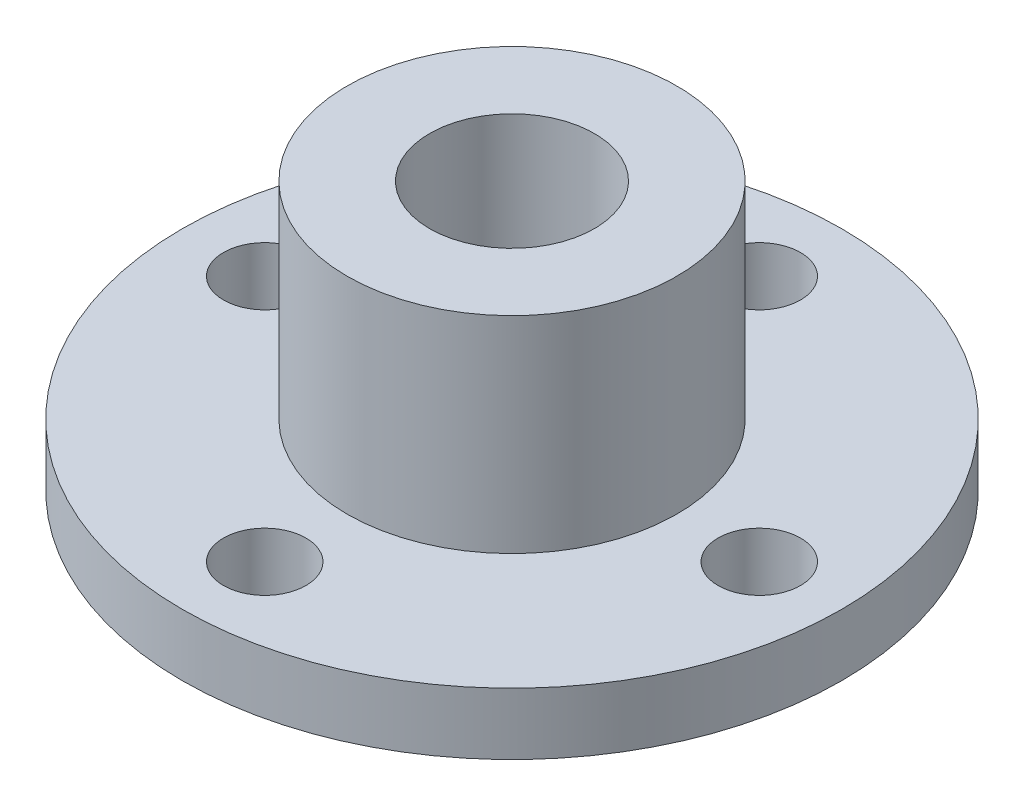
from build123d import *

# Parameters (mm, degrees)
SKETCH2_R           = 16
SKETCH2_R_2         = 2
BOSS_EXTRUDE1_DEPTH = 3
SKETCH3_R           = 8
SKETCH3_R_2         = 4
BOSS_EXTRUDE2_DEPTH = 10
SKETCH4_R           = 2
CUT_EXTRUDE1_DEPTH  = 10


with BuildPart() as part:
    # Sketch2 → Boss-Extrude1 (new body)
    with BuildSketch(Plane(origin=(0, 0, 0), x_dir=(1, 0, 0), z_dir=(0, 1, 0))):
        Circle(SKETCH2_R)
        with Locations((0, 12)):
            Circle(SKETCH2_R_2, mode=Mode.SUBTRACT)
        with Locations((-12, 0)):
            Circle(SKETCH2_R_2, mode=Mode.SUBTRACT)
        with Locations((12, 0)):
            Circle(SKETCH2_R_2, mode=Mode.SUBTRACT)
    extrude(amount=BOSS_EXTRUDE1_DEPTH)

    # Sketch3 → Boss-Extrude2 (add)
    with BuildSketch(Plane(origin=(0, 3, 0), x_dir=(1, 0, 0), z_dir=(0, 1, 0))):
        Circle(SKETCH3_R)
        Circle(SKETCH3_R_2, mode=Mode.SUBTRACT)
    extrude(amount=BOSS_EXTRUDE2_DEPTH)

    # Sketch4 → Cut-Extrude1 (cut)
    with BuildSketch(Plane(origin=(0, 3, 0), x_dir=(1, 0, 0), z_dir=(0, 1, 0))):
        with Locations((0, -12)):
            Circle(SKETCH4_R)
    extrude(amount=-CUT_EXTRUDE1_DEPTH, mode=Mode.SUBTRACT)


solid = part.part
